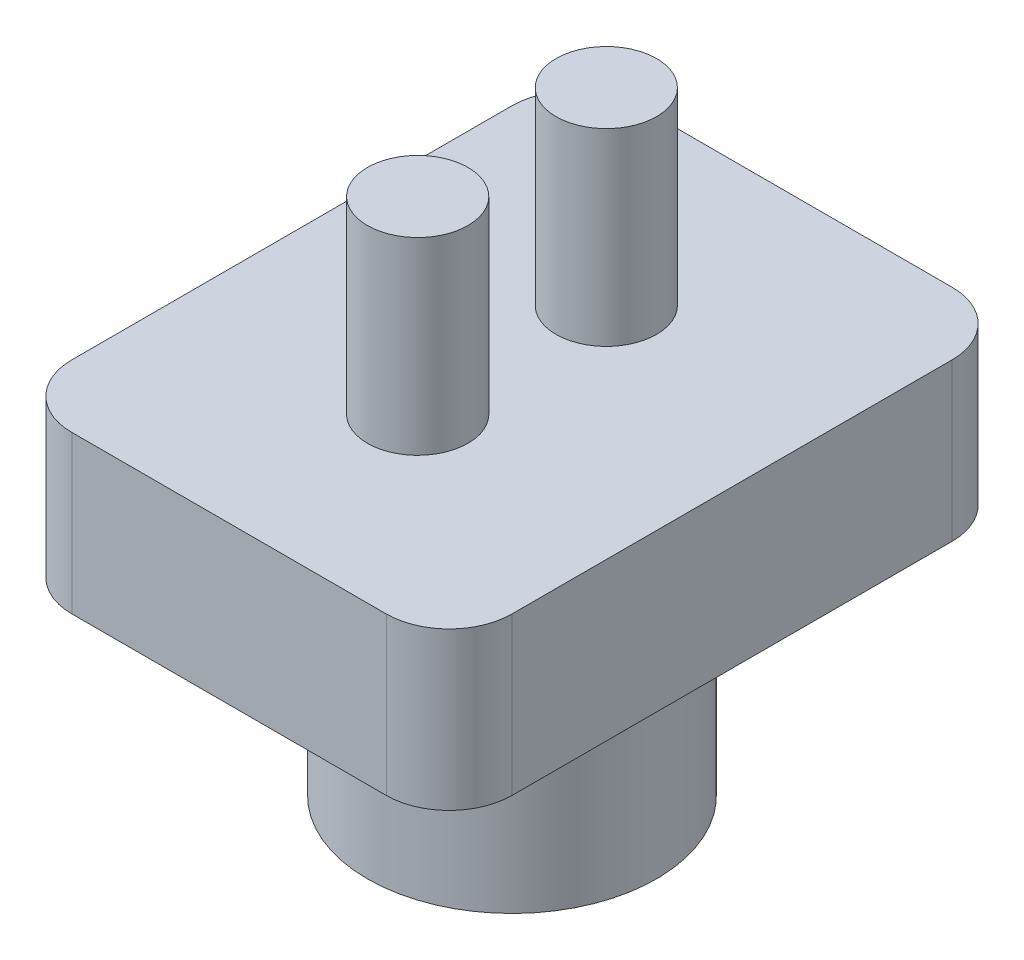
from build123d import *

# Parameters (mm, degrees)
SKETCH1_R           = 4.6
SKETCH1_R_2         = 2.8
BOSS_EXTRUDE1_DEPTH = 7
BOSS_EXTRUDE2_START = 7
SKETCH1_3_W         = 14
SKETCH1_3_H         = 18
BOSS_EXTRUDE2_DEPTH = 5
SKETCH2_R           = 1.6
BOSS_EXTRUDE3_DEPTH = 6
FILLET1_R           = 2


with BuildPart() as part:
    # Sketch1 → Boss-Extrude1 (new body)
    with BuildSketch(Plane(origin=(0, 0, 0), x_dir=(1, 0, 0), z_dir=(0, 1, 0))):
        Circle(SKETCH1_R)
        Circle(SKETCH1_R_2, mode=Mode.SUBTRACT)
    extrude(amount=BOSS_EXTRUDE1_DEPTH)

    # Sketch1_3 → Boss-Extrude2 (add)
    with BuildSketch(Plane(origin=(0, 0, 0), x_dir=(1, 0, 0), z_dir=(0, 1, 0)).offset(BOSS_EXTRUDE2_START)):
        Rectangle(SKETCH1_3_W, SKETCH1_3_H)
    extrude(amount=BOSS_EXTRUDE2_DEPTH)

    # Sketch2 → Boss-Extrude3 (add)
    with BuildSketch(Plane(origin=(0, 12, 0), x_dir=(1, 0, 0), z_dir=(0, 1, 0))):
        with Locations((0, 3)):
            Circle(SKETCH2_R)
        with Locations((0, -3)):
            Circle(SKETCH2_R)
    extrude(amount=BOSS_EXTRUDE3_DEPTH)

    # Fillet1
    fillet1_edges = [part.edges().sort_by_distance(p)[0] for p in [
        (7, 9.5, 9),
        (-7, 9.5, 9),
        (-7, 9.5, -9),
        (7, 9.5, -9),
    ]]
    fillet(fillet1_edges, radius=FILLET1_R)


solid = part.part
